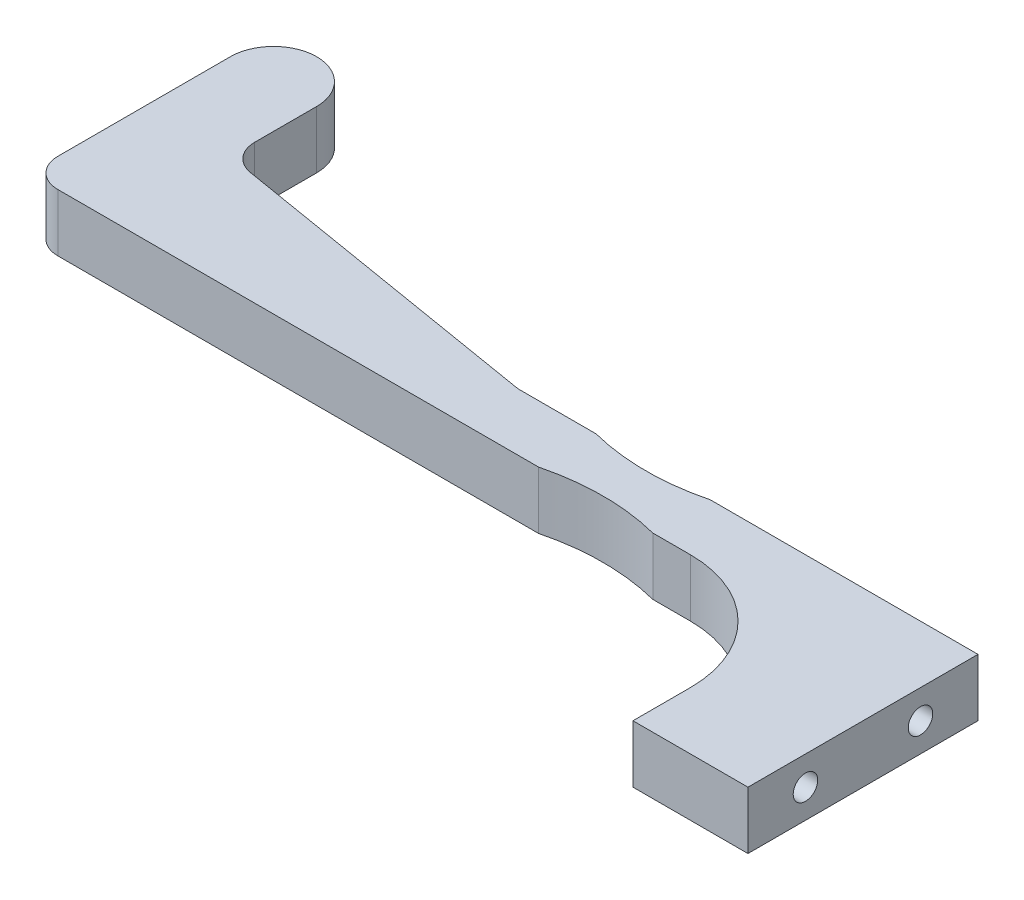
from build123d import *

# Parameters (mm, degrees)
BOSS_EXTRUDE1_DEPTH       = 6.35
FILLET1_R                 = 3.175
FILLET2_R                 = 12.7
F_6_32_TAPPED_HOLE1_D     = 2.7051
F_6_32_TAPPED_HOLE1_DEPTH = 16.6624
F_6_32_TAPPED_HOLE1_TIP   = 0.81269403
CUT_EXTRUDE1_DEPTH        = 7.3500001


with BuildPart() as part:
    # Sketch1 → Boss-Extrude1 (new body)
    with BuildSketch(Plane(origin=(0, 0, 0), x_dir=(1, 0, 0), z_dir=(0, 1, 0))):
        with BuildLine():
            Line((4.7625, -4.7625), (4.7625, -14.2875))
            Line((4.7625, -14.2875), (42.8625, -20.6375))
            Line((42.8625, -20.6375), (80.9625, -20.6375))
            Line((80.9625, -20.6375), (93.6625, -20.6375))
            Line((93.6625, -20.6375), (93.6625, -46.0375))
            Line((93.6625, -46.0375), (80.9625, -46.0375))
            Line((80.9625, -46.0375), (80.9625, -26.9875))
            Line((80.9625, -26.9875), (-4.7625, -26.9875))
            Line((-4.7625, -26.9875), (-4.7625, -4.7625))
            ThreePointArc((-4.7625, -4.7625), (0, 0), (4.7625, -4.7625))
        make_face()
    extrude(amount=BOSS_EXTRUDE1_DEPTH)

    # Fillet1
    fillet1_edges = [part.edges().sort_by_distance(p)[0] for p in [
        (42.8625, 3.175, 20.6375),
        (-4.7625, 3.175, 26.9875),
        (4.7625, 3.175, 14.2875),
    ]]
    fillet(fillet1_edges, radius=FILLET1_R)

    # Fillet2
    fillet2_edges = [part.edges().sort_by_distance(p)[0] for p in [
        (80.9625, 3.175, 26.9875),
    ]]
    fillet(fillet2_edges, radius=FILLET2_R)

    # #6-32 Tapped Hole1
    with Locations(Plane(origin=(93.6625, 0, 0), x_dir=(0, 0, -1), z_dir=(1, 0, 0))):
        with Locations((-39.6875, 3.175), (-26.9875, 3.175)):
            Hole(F_6_32_TAPPED_HOLE1_D / 2, depth=F_6_32_TAPPED_HOLE1_DEPTH)
            with Locations((0, 0, -(F_6_32_TAPPED_HOLE1_DEPTH + F_6_32_TAPPED_HOLE1_TIP / 2))):  # 118° drill point
                Cone(0, F_6_32_TAPPED_HOLE1_D / 2, F_6_32_TAPPED_HOLE1_TIP, mode=Mode.SUBTRACT)

    # Sketch4 → Cut-Extrude1 (cut, through all)
    with BuildSketch(Plane(origin=(0, 6.35, 0), x_dir=(1, 0, 0), z_dir=(0, 1, 0))):
        with BuildLine():
            Line((40.779910828, -32.744004197), (74.829702789, -32.744004197))
            ThreePointArc((74.829702789, -32.744004197), (57.804806809, -26.19375), (40.779910828, -32.744004197))
        make_face()
        with BuildLine():
            Line((40.610356343, -14.726459899), (74.999257275, -14.726459899))
            ThreePointArc((74.999257275, -14.726459899), (57.804806809, -21.43125), (40.610356343, -14.726459899))
        make_face()
    extrude(amount=-CUT_EXTRUDE1_DEPTH, mode=Mode.SUBTRACT)


solid = part.part
